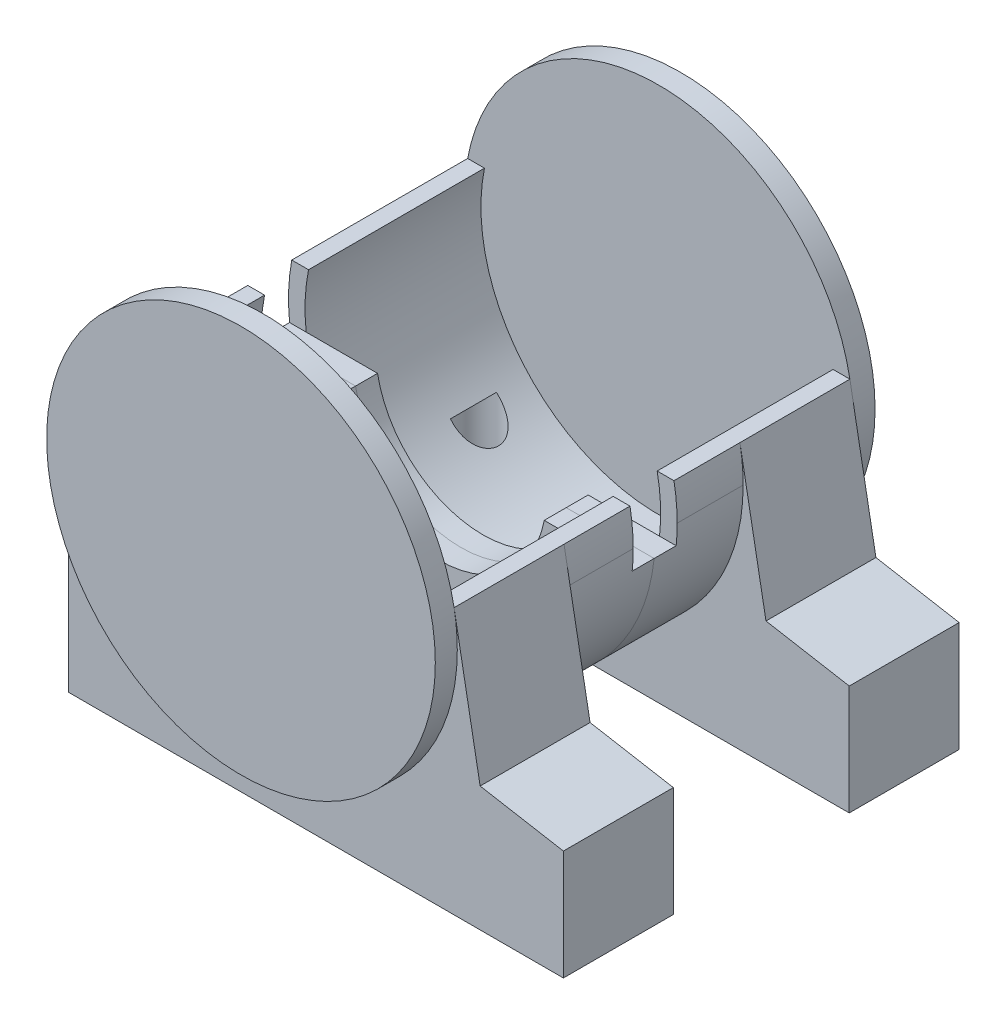
from build123d import *

# Parameters (mm, degrees)
SKETCH1_R           = 17.675
BOSS_EXTRUDE1_DEPTH = 2
BOSS_EXTRUDE2_START = 16
BOSS_EXTRUDE2_DEPTH = 16
BOSS_EXTRUDE3_START = 2
BOSS_EXTRUDE3_DEPTH = 2
BOSS_EXTRUDE4_START = 10
BOSS_EXTRUDE4_DEPTH = 10
SKETCH5_R           = 2.1
CUT_EXTRUDE3_DEPTH  = 10


with BuildPart() as part:
    # Sketch1 → Boss-Extrude1 (new body)
    with BuildSketch(Plane.XY):
        Circle(SKETCH1_R)
    extrude(amount=-BOSS_EXTRUDE1_DEPTH)

    # Sketch1_4 → Boss-Extrude2 (add)
    with BuildSketch(Plane.XY.offset(BOSS_EXTRUDE2_START)):
        with BuildLine():
            Line((-15.855302741, 3.2), (-17.382911868, 3.2))
            ThreePointArc((-17.382911868, 3.2), (-1.606651446, -17.6018265), (17.675, 0))
            ThreePointArc((17.675, 0), (17.6018265, 1.606651446), (17.382911868, 3.2))
            Line((17.382911868, 3.2), (15.855302741, 3.2))
            ThreePointArc((15.855302741, 3.2), (16.094877241, 1.607965045), (16.175, 0))
            ThreePointArc((16.175, 0), (-1.607965045, -16.094877241), (-15.855302741, 3.2))
        make_face()
    extrude(amount=-BOSS_EXTRUDE2_DEPTH)

    # Sketch2 → Boss-Extrude3 (add)
    with BuildSketch(Plane.XY.offset(16).offset(BOSS_EXTRUDE3_START)):
        with BuildLine():
            ThreePointArc((-17.580529002, -1.825), (0, -17.675), (17.580529002, -1.825))
            Line((17.580529002, -1.825), (9.580529002, -1.825))
            ThreePointArc((9.580529002, -1.825), (0, -9.752802724), (-9.580529002, -1.825))
            Line((-9.580529002, -1.825), (-17.580529002, -1.825))
        make_face()
    extrude(amount=-BOSS_EXTRUDE3_DEPTH)

    # Sketch3 → Boss-Extrude4 (add)
    with BuildSketch(Plane.XY.offset(BOSS_EXTRUDE4_START)):
        with BuildLine():
            Line((-17.675, -21.0022), (27.325, -21.0022))
            Line((27.325, -21.0022), (27.325, -11.0022))
            Line((27.325, -11.0022), (19.751545283, -9.666795596))
            Line((19.751545283, -9.666795596), (17.382911868, 3.2))
            ThreePointArc((17.382911868, 3.2), (1.606651446, -17.6018265), (-17.675, 0))
            Line((-17.675, 0), (-17.675, -21.0022))
        make_face()
    extrude(amount=-BOSS_EXTRUDE4_DEPTH)

    # Sketch5 → Cut-Extrude3 (cut)
    with BuildSketch(Plane.XZ.offset(21.0022)):
        with Locations((-11.675, 5)):
            Circle(SKETCH5_R)
        with Locations((21.325, 5)):
            Circle(SKETCH5_R)
    extrude(amount=-CUT_EXTRUDE3_DEPTH, mode=Mode.SUBTRACT)


with BuildPart() as body_2:
    # Mirror1: mirrored copy
    add(part.part.mirror(Plane.XY.offset(18)))


solid = Compound([part.part, body_2.part])
